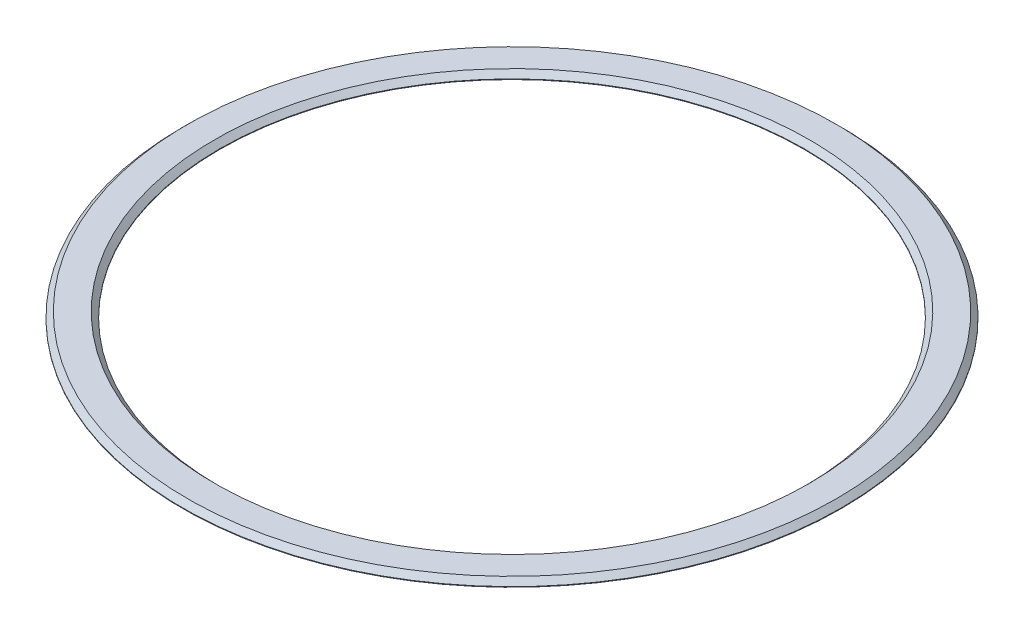
from build123d import *


with BuildPart() as part:
    # 草图1 → 旋转1 (revolve)
    with BuildSketch(Plane.XY):
        Polygon((-113.760743693, 8.4), (-113.760743693, 8.2), (-100.910512847, 8.2), (-100.910512847, 8.4), (-102.710512847, 10.2), (-111.960743693, 10.2), align=None)
    revolve(axis=Axis((0, 0, 0), (0, 1, 0)))


solid = part.part
